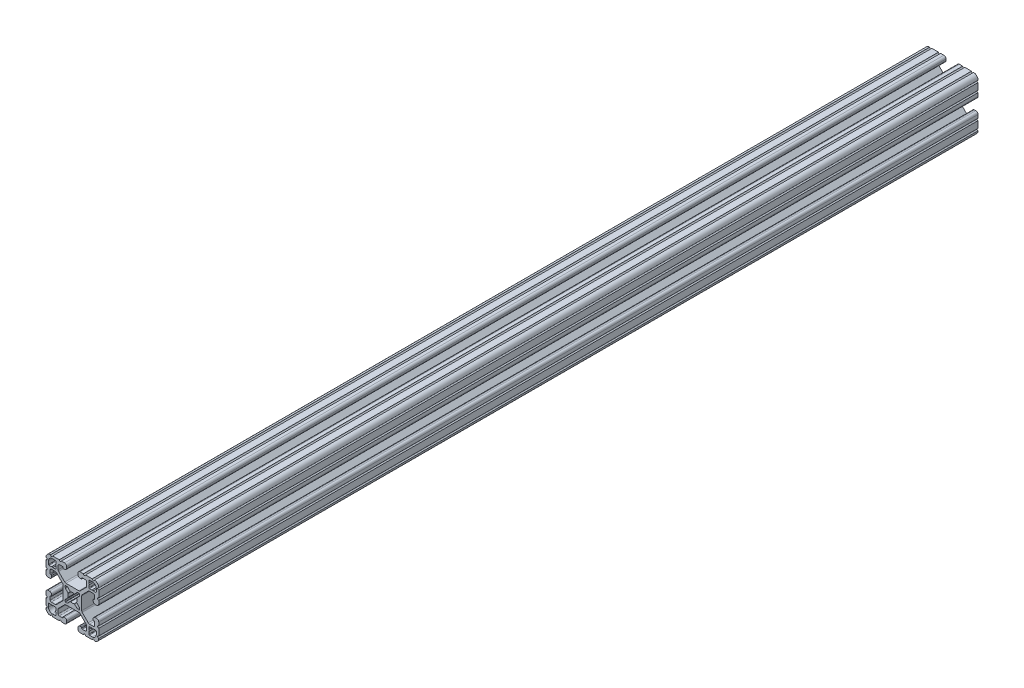
from build123d import *

# Parameters (mm, degrees)
EXTRUDE1_DEPTH = 635


with BuildPart() as part:
    # Sketch1 → Extrude1 (new body)
    with BuildSketch(Plane.XY):
        with BuildLine():
            Line((6.349777007, -14.984831919), (5.653061318, -14.984831848))
            ThreePointArc((5.653061318, -14.984831848), (4.539002167, -15.446080098), (4.077754017, -16.560139291))
            Line((4.077754017, -16.560139291), (4.077753935, -17.474692556))
            ThreePointArc((4.077753935, -17.474692556), (4.539002158, -18.588751741), (5.653061362, -19.049999918))
            Line((5.653061362, -19.049999918), (7.975599859, -19.05))
            ThreePointArc((7.975599859, -19.05), (8.737599929, -18.288), (9.4996, -19.05))
            Line((9.4996, -19.05), (14.298091988, -19.05))
            ThreePointArc((14.298091988, -19.05), (15.05987163, -18.288000032), (15.822092002, -19.049559142))
            ThreePointArc((15.822092002, -19.049559142), (18.110316678, -18.129769245), (19.049898398, -15.849599993))
            ThreePointArc((19.049898398, -15.849599993), (18.288000002, -15.087549199), (19.05, -14.3256))
            Line((19.05, -14.3256), (19.05, -9.499600141))
            ThreePointArc((19.05, -9.499600141), (18.288, -8.737600071), (19.05, -7.9756))
            Line((19.05, -7.9756), (19.05, -5.653061359))
            ThreePointArc((19.05, -5.653061359), (18.588751763, -4.53900218), (17.474692553, -4.077754017))
            Line((17.474692553, -4.077754017), (16.560139293, -4.077753935))
            ThreePointArc((16.560139293, -4.077753935), (15.446080122, -4.539002143), (14.98483193, -5.653061321))
            Line((14.98483193, -5.653061321), (14.984831848, -6.349776986))
            ThreePointArc((14.984831848, -6.349776986), (15.096428348, -6.619420887), (15.366075744, -6.731008942))
            Line((15.366075744, -6.731008942), (15.696937609, -6.730998691))
            ThreePointArc((15.696937609, -6.730998691), (15.966583472, -6.842585282), (16.078181438, -7.112226438))
            Line((16.078181438, -7.112226438), (16.078207121, -9.396837814))
            ThreePointArc((16.078207121, -9.396837814), (15.817838504, -10.026619018), (15.188068118, -10.287013801))
            Line((15.188068118, -10.287013801), (12.352560476, -10.287103022))
            ThreePointArc((12.352560476, -10.287103022), (11.865894357, -10.190173629), (11.453520834, -9.914153164))
            Line((11.453520834, -9.914153164), (7.114725376, -5.565926641))
            ThreePointArc((7.114725376, -5.565926641), (6.840134749, -5.154247475), (6.7437254, -4.668876499))
            Line((6.7437254, -4.668876499), (6.7437254, 4.641368628))
            ThreePointArc((6.7437254, 4.641368628), (6.840134749, 5.126739605), (7.114725376, 5.53841877))
            Line((7.114725376, 5.53841877), (11.480968187, 9.914152308))
            ThreePointArc((11.480968187, 9.914152308), (11.89334171, 10.190172773), (12.380007829, 10.287102166))
            Line((12.380007829, 10.287102166), (15.188068116, 10.287014567))
            ThreePointArc((15.188068116, 10.287014567), (15.817838279, 10.026619243), (16.078206356, 9.396837815))
            Line((16.078206356, 9.396837815), (16.078181509, 7.1122265))
            ThreePointArc((16.078181509, 7.1122265), (15.966583514, 6.842585324), (15.696937607, 6.730998762))
            Line((15.696937607, 6.730998762), (15.366075744, 6.731009012))
            ThreePointArc((15.366075744, 6.731009012), (15.096428376, 6.619420915), (14.984831919, 6.349777007))
            Line((14.984831919, 6.349777007), (14.984831848, 5.653061318))
            ThreePointArc((14.984831848, 5.653061318), (15.446080098, 4.539002167), (16.560139291, 4.077754017))
            Line((16.560139291, 4.077754017), (17.474692556, 4.077753935))
            ThreePointArc((17.474692556, 4.077753935), (18.588751741, 4.539002158), (19.049999918, 5.653061362))
            Line((19.049999918, 5.653061362), (19.05, 7.975599859))
            ThreePointArc((19.05, 7.975599859), (18.288, 8.737599929), (19.05, 9.4996))
            Line((19.05, 9.4996), (19.05, 14.298091988))
            ThreePointArc((19.05, 14.298091988), (18.288000032, 15.05987163), (19.049559142, 15.822092002))
            ThreePointArc((19.049559142, 15.822092002), (18.129769245, 18.110316678), (15.849599993, 19.049898398))
            ThreePointArc((15.849599993, 19.049898398), (15.087549199, 18.288000002), (14.3256, 19.05))
            Line((14.3256, 19.05), (9.499600141, 19.05))
            ThreePointArc((9.499600141, 19.05), (8.737600071, 18.288), (7.9756, 19.05))
            Line((7.9756, 19.05), (5.653061359, 19.05))
            ThreePointArc((5.653061359, 19.05), (4.53900218, 18.588751763), (4.077754017, 17.474692553))
            Line((4.077754017, 17.474692553), (4.077753935, 16.560139293))
            ThreePointArc((4.077753935, 16.560139293), (4.539002143, 15.446080122), (5.653061321, 14.98483193))
            Line((5.653061321, 14.98483193), (6.349776986, 14.984831848))
            ThreePointArc((6.349776986, 14.984831848), (6.619420887, 15.096428348), (6.731008942, 15.366075744))
            Line((6.731008942, 15.366075744), (6.730998691, 15.696937609))
            ThreePointArc((6.730998691, 15.696937609), (6.842585282, 15.966583472), (7.112226438, 16.078181438))
            Line((7.112226438, 16.078181438), (9.396837814, 16.078207121))
            ThreePointArc((9.396837814, 16.078207121), (10.026619018, 15.817838504), (10.287013801, 15.188068118))
            Line((10.287013801, 15.188068118), (10.287103022, 12.352560476))
            ThreePointArc((10.287103022, 12.352560476), (10.190173629, 11.865894357), (9.914153164, 11.453520834))
            Line((9.914153164, 11.453520834), (5.565926641, 7.114725376))
            ThreePointArc((5.565926641, 7.114725376), (5.154247475, 6.840134749), (4.668876499, 6.7437254))
            Line((4.668876499, 6.7437254), (-4.641368628, 6.7437254))
            ThreePointArc((-4.641368628, 6.7437254), (-5.126739605, 6.840134749), (-5.53841877, 7.114725376))
            Line((-5.53841877, 7.114725376), (-9.914152308, 11.480968187))
            ThreePointArc((-9.914152308, 11.480968187), (-10.190172773, 11.89334171), (-10.287102166, 12.380007829))
            Line((-10.287102166, 12.380007829), (-10.287014567, 15.188068116))
            ThreePointArc((-10.287014567, 15.188068116), (-10.026619243, 15.817838279), (-9.396837815, 16.078206356))
            Line((-9.396837815, 16.078206356), (-7.1122265, 16.078181509))
            ThreePointArc((-7.1122265, 16.078181509), (-6.842585324, 15.966583514), (-6.730998762, 15.696937607))
            Line((-6.730998762, 15.696937607), (-6.731008942, 15.366075744))
            ThreePointArc((-6.731008942, 15.366075744), (-6.619420905, 15.096428366), (-6.349777007, 14.984831919))
            Line((-6.349777007, 14.984831919), (-5.653061318, 14.984831848))
            ThreePointArc((-5.653061318, 14.984831848), (-4.539002167, 15.446080098), (-4.077754017, 16.560139291))
            Line((-4.077754017, 16.560139291), (-4.077753935, 17.474692556))
            ThreePointArc((-4.077753935, 17.474692556), (-4.539002158, 18.588751741), (-5.653061362, 19.049999918))
            Line((-5.653061362, 19.049999918), (-7.975599859, 19.05))
            ThreePointArc((-7.975599859, 19.05), (-8.737599929, 18.288), (-9.4996, 19.05))
            Line((-9.4996, 19.05), (-14.298091988, 19.05))
            ThreePointArc((-14.298091988, 19.05), (-15.05987163, 18.288000032), (-15.822092002, 19.049559142))
            ThreePointArc((-15.822092002, 19.049559142), (-18.110316678, 18.129769245), (-19.049898398, 15.849599993))
            ThreePointArc((-19.049898398, 15.849599993), (-18.288000002, 15.087549199), (-19.05, 14.3256))
            Line((-19.05, 14.3256), (-19.05, 9.499600141))
            ThreePointArc((-19.05, 9.499600141), (-18.288, 8.737600071), (-19.05, 7.9756))
            Line((-19.05, 7.9756), (-19.05, 5.653061359))
            ThreePointArc((-19.05, 5.653061359), (-18.588751763, 4.53900218), (-17.474692553, 4.077754017))
            Line((-17.474692553, 4.077754017), (-16.560139293, 4.077753935))
            ThreePointArc((-16.560139293, 4.077753935), (-15.446080122, 4.539002143), (-14.98483193, 5.653061321))
            Line((-14.98483193, 5.653061321), (-14.984831848, 6.349776986))
            ThreePointArc((-14.984831848, 6.349776986), (-15.096428348, 6.619420887), (-15.366075744, 6.731008942))
            Line((-15.366075744, 6.731008942), (-15.696937609, 6.730998691))
            ThreePointArc((-15.696937609, 6.730998691), (-15.966583472, 6.842585283), (-16.078181438, 7.112226438))
            Line((-16.078181438, 7.112226438), (-16.078207121, 9.396837814))
            ThreePointArc((-16.078207121, 9.396837814), (-15.817838504, 10.026619018), (-15.188068118, 10.287013802))
            Line((-15.188068118, 10.287013802), (-12.352560476, 10.287103022))
            ThreePointArc((-12.352560476, 10.287103022), (-11.865894357, 10.190173629), (-11.453520834, 9.914153164))
            Line((-11.453520834, 9.914153164), (-7.114725376, 5.565926641))
            ThreePointArc((-7.114725376, 5.565926641), (-6.840134749, 5.154247475), (-6.7437254, 4.668876499))
            Line((-6.7437254, 4.668876499), (-6.7437254, -4.641368628))
            ThreePointArc((-6.7437254, -4.641368628), (-6.840134749, -5.126739605), (-7.114725376, -5.53841877))
            Line((-7.114725376, -5.53841877), (-11.480968187, -9.914152308))
            ThreePointArc((-11.480968187, -9.914152308), (-11.89334171, -10.190172773), (-12.380007829, -10.287102166))
            Line((-12.380007829, -10.287102166), (-15.188068116, -10.287014567))
            ThreePointArc((-15.188068116, -10.287014567), (-15.817838279, -10.026619243), (-16.078206356, -9.396837815))
            Line((-16.078206356, -9.396837815), (-16.078181509, -7.1122265))
            ThreePointArc((-16.078181509, -7.1122265), (-15.966583514, -6.842585324), (-15.696937607, -6.730998762))
            Line((-15.696937607, -6.730998762), (-15.366075744, -6.731009012))
            ThreePointArc((-15.366075744, -6.731009012), (-15.096428376, -6.619420915), (-14.984831919, -6.349777007))
            Line((-14.984831919, -6.349777007), (-14.984831848, -5.653061318))
            ThreePointArc((-14.984831848, -5.653061318), (-15.446080098, -4.539002167), (-16.560139291, -4.077754017))
            Line((-16.560139291, -4.077754017), (-17.474692556, -4.077753935))
            ThreePointArc((-17.474692556, -4.077753935), (-18.588751741, -4.539002158), (-19.049999918, -5.653061362))
            Line((-19.049999918, -5.653061362), (-19.05, -7.975599859))
            ThreePointArc((-19.05, -7.975599859), (-18.288, -8.737599929), (-19.05, -9.4996))
            Line((-19.05, -9.4996), (-19.05, -14.298091988))
            ThreePointArc((-19.05, -14.298091988), (-18.288000032, -15.05987163), (-19.049559142, -15.822092002))
            ThreePointArc((-19.049559142, -15.822092002), (-18.129769245, -18.110316678), (-15.849599993, -19.049898398))
            ThreePointArc((-15.849599993, -19.049898398), (-15.087549199, -18.288000002), (-14.3256, -19.05))
            Line((-14.3256, -19.05), (-9.499600141, -19.05))
            ThreePointArc((-9.499600141, -19.05), (-8.737600071, -18.288), (-7.9756, -19.05))
            Line((-7.9756, -19.05), (-5.653061359, -19.05))
            ThreePointArc((-5.653061359, -19.05), (-4.53900218, -18.588751763), (-4.077754017, -17.474692553))
            Line((-4.077754017, -17.474692553), (-4.077753935, -16.560139293))
            ThreePointArc((-4.077753935, -16.560139293), (-4.539002143, -15.446080122), (-5.653061321, -14.98483193))
            Line((-5.653061321, -14.98483193), (-6.349776986, -14.984831848))
            ThreePointArc((-6.349776986, -14.984831848), (-6.619420887, -15.096428348), (-6.731008942, -15.366075744))
            Line((-6.731008942, -15.366075744), (-6.730998691, -15.696937609))
            ThreePointArc((-6.730998691, -15.696937609), (-6.842585282, -15.966583472), (-7.112226438, -16.078181438))
            Line((-7.112226438, -16.078181438), (-9.396837814, -16.078207121))
            ThreePointArc((-9.396837814, -16.078207121), (-10.026619018, -15.817838504), (-10.287013801, -15.188068118))
            Line((-10.287013801, -15.188068118), (-10.287103022, -12.352560476))
            ThreePointArc((-10.287103022, -12.352560476), (-10.190173629, -11.865894357), (-9.914153164, -11.453520834))
            Line((-9.914153164, -11.453520834), (-5.565926641, -7.114725376))
            ThreePointArc((-5.565926641, -7.114725376), (-5.154247475, -6.840134749), (-4.668876499, -6.7437254))
            Line((-4.668876499, -6.7437254), (4.641368628, -6.7437254))
            ThreePointArc((4.641368628, -6.7437254), (5.126739605, -6.840134749), (5.53841877, -7.114725376))
            Line((5.53841877, -7.114725376), (9.914152308, -11.480968187))
            ThreePointArc((9.914152308, -11.480968187), (10.190172773, -11.89334171), (10.287102166, -12.380007829))
            Line((10.287102166, -12.380007829), (10.287014567, -15.188068116))
            ThreePointArc((10.287014567, -15.188068116), (10.026619243, -15.817838279), (9.396837815, -16.078206356))
            Line((9.396837815, -16.078206356), (7.1122265, -16.078181509))
            ThreePointArc((7.1122265, -16.078181509), (6.842585324, -15.966583514), (6.730998762, -15.696937607))
            Line((6.730998762, -15.696937607), (6.731008942, -15.366075744))
            ThreePointArc((6.731008942, -15.366075744), (6.619420905, -15.096428366), (6.349777007, -14.984831919))
        make_face()
        with BuildLine():
            Line((1.582347442, 3.198793543), (3.292097227, 4.908543328))
            ThreePointArc((3.292097227, 4.908543328), (3.580509584, 5.101254304), (3.920715155, 5.1689254))
            Line((3.920715155, 5.1689254), (4.9149254, 5.1689254))
            ThreePointArc((4.9149254, 5.1689254), (5.094530522, 5.094530522), (5.1689254, 4.9149254))
            Line((5.1689254, 4.9149254), (5.1689254, 3.920715155))
            ThreePointArc((5.1689254, 3.920715155), (5.101254304, 3.580509584), (4.908543328, 3.292097227))
            Line((4.908543328, 3.292097227), (3.198793543, 1.582347442))
            ThreePointArc((3.198793543, 1.582347442), (3.095711236, 1.393016011), (3.111879183, 1.178048687))
            ThreePointArc((3.111879183, 1.178048687), (3.3274, 0), (3.111879183, -1.178048687))
            ThreePointArc((3.111879183, -1.178048687), (3.095711236, -1.393016011), (3.198793543, -1.582347442))
            Line((3.198793543, -1.582347442), (4.908543328, -3.292097227))
            ThreePointArc((4.908543328, -3.292097227), (5.101254304, -3.580509584), (5.1689254, -3.920715155))
            Line((5.1689254, -3.920715155), (5.1689254, -4.9149254))
            ThreePointArc((5.1689254, -4.9149254), (5.094530522, -5.094530522), (4.9149254, -5.1689254))
            Line((4.9149254, -5.1689254), (3.920715155, -5.1689254))
            ThreePointArc((3.920715155, -5.1689254), (3.580509584, -5.101254304), (3.292097227, -4.908543328))
            Line((3.292097227, -4.908543328), (1.582347442, -3.198793543))
            ThreePointArc((1.582347442, -3.198793543), (1.393016011, -3.095711236), (1.178048687, -3.111879183))
            ThreePointArc((1.178048687, -3.111879183), (0, -3.3274), (-1.178048687, -3.111879183))
            ThreePointArc((-1.178048687, -3.111879183), (-1.393016011, -3.095711236), (-1.582347442, -3.198793543))
            Line((-1.582347442, -3.198793543), (-3.292097227, -4.908543328))
            ThreePointArc((-3.292097227, -4.908543328), (-3.580509584, -5.101254304), (-3.920715155, -5.1689254))
            Line((-3.920715155, -5.1689254), (-4.9149254, -5.1689254))
            ThreePointArc((-4.9149254, -5.1689254), (-5.094530522, -5.094530522), (-5.1689254, -4.9149254))
            Line((-5.1689254, -4.9149254), (-5.1689254, -3.920715155))
            ThreePointArc((-5.1689254, -3.920715155), (-5.101254304, -3.580509584), (-4.908543328, -3.292097227))
            Line((-4.908543328, -3.292097227), (-3.198793543, -1.582347442))
            ThreePointArc((-3.198793543, -1.582347442), (-3.095711236, -1.393016011), (-3.111879183, -1.178048687))
            ThreePointArc((-3.111879183, -1.178048687), (-3.3274, 0), (-3.111879183, 1.178048687))
            ThreePointArc((-3.111879183, 1.178048687), (-3.095711236, 1.393016011), (-3.198793543, 1.582347442))
            Line((-3.198793543, 1.582347442), (-4.908543328, 3.292097227))
            ThreePointArc((-4.908543328, 3.292097227), (-5.101254304, 3.580509584), (-5.1689254, 3.920715155))
            Line((-5.1689254, 3.920715155), (-5.1689254, 4.9149254))
            ThreePointArc((-5.1689254, 4.9149254), (-5.094530522, 5.094530522), (-4.9149254, 5.1689254))
            Line((-4.9149254, 5.1689254), (-3.920715155, 5.1689254))
            ThreePointArc((-3.920715155, 5.1689254), (-3.580509584, 5.101254304), (-3.292097227, 4.908543328))
            Line((-3.292097227, 4.908543328), (-1.582347442, 3.198793543))
            ThreePointArc((-1.582347442, 3.198793543), (-1.393016011, 3.095711236), (-1.178048687, 3.111879183))
            ThreePointArc((-1.178048687, 3.111879183), (0, 3.3274), (1.178048687, 3.111879183))
            ThreePointArc((1.178048687, 3.111879183), (1.393016011, 3.095711236), (1.582347442, 3.198793543))
        make_face(mode=Mode.SUBTRACT)
        with BuildLine():
            Line((-11.8669054, 14.019430433), (-11.8669054, 12.24788))
            ThreePointArc((-11.8669054, 12.24788), (-11.978497716, 11.978472316), (-12.2479054, 11.86688))
            Line((-12.2479054, 11.86688), (-14.019455833, 11.86688))
            ThreePointArc((-14.019455833, 11.86688), (-14.020427836, 11.867073341), (-14.021251865, 11.867623929))
            Line((-14.021251865, 11.867623929), (-14.557512425, 12.403872831))
            ThreePointArc((-14.557512425, 12.403872831), (-14.559308484, 12.404616761), (-14.561104527, 12.403872792))
            Line((-14.561104527, 12.403872792), (-15.097341694, 11.867623968))
            ThreePointArc((-15.097341694, 11.867623968), (-15.098165736, 11.867073351), (-15.099137765, 11.86688))
            Line((-15.099137765, 11.86688), (-16.8707054, 11.86688))
            ThreePointArc((-16.8707054, 11.86688), (-17.140113084, 11.978472316), (-17.2517054, 12.24788))
            Line((-17.2517054, 12.24788), (-17.2517054, 14.45768))
            ThreePointArc((-17.2517054, 14.45768), (-16.433361747, 16.433336347), (-14.4577054, 17.25168))
            Line((-14.4577054, 17.25168), (-12.2479054, 17.25168))
            ThreePointArc((-12.2479054, 17.25168), (-11.978497716, 17.140087684), (-11.8669054, 16.87068))
            Line((-11.8669054, 16.87068), (-11.8669054, 15.099112365))
            ThreePointArc((-11.8669054, 15.099112365), (-11.867098751, 15.098140336), (-11.867649368, 15.097316294))
            Line((-11.867649368, 15.097316294), (-12.403898192, 14.561079127))
            ThreePointArc((-12.403898192, 14.561079127), (-12.40464216, 14.559283084), (-12.403898231, 14.557487025))
            Line((-12.403898231, 14.557487025), (-11.867649329, 14.021226465))
            ThreePointArc((-11.867649329, 14.021226465), (-11.867098741, 14.020402437), (-11.8669054, 14.019430433))
        make_face(mode=Mode.SUBTRACT)
        with BuildLine():
            Line((-14.019430433, -11.8669054), (-12.24788, -11.8669054))
            ThreePointArc((-12.24788, -11.8669054), (-11.978472316, -11.978497716), (-11.86688, -12.2479054))
            Line((-11.86688, -12.2479054), (-11.86688, -14.019455833))
            ThreePointArc((-11.86688, -14.019455833), (-11.867073341, -14.020427836), (-11.867623929, -14.021251865))
            Line((-11.867623929, -14.021251865), (-12.403872831, -14.557512425))
            ThreePointArc((-12.403872831, -14.557512425), (-12.404616761, -14.559308484), (-12.403872792, -14.561104527))
            Line((-12.403872792, -14.561104527), (-11.867623968, -15.097341694))
            ThreePointArc((-11.867623968, -15.097341694), (-11.867073351, -15.098165736), (-11.86688, -15.099137765))
            Line((-11.86688, -15.099137765), (-11.86688, -16.8707054))
            ThreePointArc((-11.86688, -16.8707054), (-11.978472316, -17.140113083), (-12.24788, -17.2517054))
            Line((-12.24788, -17.2517054), (-14.45768, -17.2517054))
            ThreePointArc((-14.45768, -17.2517054), (-16.433336347, -16.433361746), (-17.25168, -14.4577054))
            Line((-17.25168, -14.4577054), (-17.25168, -12.2479054))
            ThreePointArc((-17.25168, -12.2479054), (-17.140087684, -11.978497716), (-16.87068, -11.8669054))
            Line((-16.87068, -11.8669054), (-15.099112365, -11.8669054))
            ThreePointArc((-15.099112365, -11.8669054), (-15.098140336, -11.867098751), (-15.097316294, -11.867649368))
            Line((-15.097316294, -11.867649368), (-14.561079127, -12.403898192))
            ThreePointArc((-14.561079127, -12.403898192), (-14.559283084, -12.40464216), (-14.557487025, -12.403898231))
            Line((-14.557487025, -12.403898231), (-14.021226465, -11.867649329))
            ThreePointArc((-14.021226465, -11.867649329), (-14.020402437, -11.867098741), (-14.019430433, -11.8669054))
        make_face(mode=Mode.SUBTRACT)
        with BuildLine():
            Line((11.8669054, -14.019430433), (11.8669054, -12.24788))
            ThreePointArc((11.8669054, -12.24788), (11.978497716, -11.978472316), (12.2479054, -11.86688))
            Line((12.2479054, -11.86688), (14.019455833, -11.86688))
            ThreePointArc((14.019455833, -11.86688), (14.020427836, -11.867073341), (14.021251865, -11.867623929))
            Line((14.021251865, -11.867623929), (14.557512425, -12.403872831))
            ThreePointArc((14.557512425, -12.403872831), (14.559308484, -12.404616761), (14.561104527, -12.403872792))
            Line((14.561104527, -12.403872792), (15.097341694, -11.867623968))
            ThreePointArc((15.097341694, -11.867623968), (15.098165736, -11.867073351), (15.099137765, -11.86688))
            Line((15.099137765, -11.86688), (16.8707054, -11.86688))
            ThreePointArc((16.8707054, -11.86688), (17.140113084, -11.978472316), (17.2517054, -12.24788))
            Line((17.2517054, -12.24788), (17.2517054, -14.45768))
            ThreePointArc((17.2517054, -14.45768), (16.433361747, -16.433336347), (14.4577054, -17.25168))
            Line((14.4577054, -17.25168), (12.2479054, -17.25168))
            ThreePointArc((12.2479054, -17.25168), (11.978497716, -17.140087684), (11.8669054, -16.87068))
            Line((11.8669054, -16.87068), (11.8669054, -15.099112365))
            ThreePointArc((11.8669054, -15.099112365), (11.867098751, -15.098140336), (11.867649368, -15.097316294))
            Line((11.867649368, -15.097316294), (12.403898192, -14.561079127))
            ThreePointArc((12.403898192, -14.561079127), (12.40464216, -14.559283084), (12.403898231, -14.557487025))
            Line((12.403898231, -14.557487025), (11.867649329, -14.021226465))
            ThreePointArc((11.867649329, -14.021226465), (11.867098741, -14.020402436), (11.8669054, -14.019430433))
        make_face(mode=Mode.SUBTRACT)
        with BuildLine():
            Line((14.019430433, 11.8669054), (12.24788, 11.8669054))
            ThreePointArc((12.24788, 11.8669054), (11.978472316, 11.978497716), (11.86688, 12.2479054))
            Line((11.86688, 12.2479054), (11.86688, 14.019455833))
            ThreePointArc((11.86688, 14.019455833), (11.867073341, 14.020427836), (11.867623929, 14.021251865))
            Line((11.867623929, 14.021251865), (12.403872831, 14.557512425))
            ThreePointArc((12.403872831, 14.557512425), (12.404616761, 14.559308484), (12.403872792, 14.561104527))
            Line((12.403872792, 14.561104527), (11.867623968, 15.097341694))
            ThreePointArc((11.867623968, 15.097341694), (11.867073351, 15.098165736), (11.86688, 15.099137765))
            Line((11.86688, 15.099137765), (11.86688, 16.8707054))
            ThreePointArc((11.86688, 16.8707054), (11.978472316, 17.140113084), (12.24788, 17.2517054))
            Line((12.24788, 17.2517054), (14.45768, 17.2517054))
            ThreePointArc((14.45768, 17.2517054), (16.433336347, 16.433361747), (17.25168, 14.4577054))
            Line((17.25168, 14.4577054), (17.25168, 12.2479054))
            ThreePointArc((17.25168, 12.2479054), (17.140087684, 11.978497716), (16.87068, 11.8669054))
            Line((16.87068, 11.8669054), (15.099112365, 11.8669054))
            ThreePointArc((15.099112365, 11.8669054), (15.098140336, 11.867098751), (15.097316294, 11.867649368))
            Line((15.097316294, 11.867649368), (14.561079127, 12.403898192))
            ThreePointArc((14.561079127, 12.403898192), (14.559283084, 12.404642161), (14.557487025, 12.403898231))
            Line((14.557487025, 12.403898231), (14.021226465, 11.867649329))
            ThreePointArc((14.021226465, 11.867649329), (14.020402436, 11.867098741), (14.019430433, 11.8669054))
        make_face(mode=Mode.SUBTRACT)
    extrude(amount=-EXTRUDE1_DEPTH)


solid = part.part
